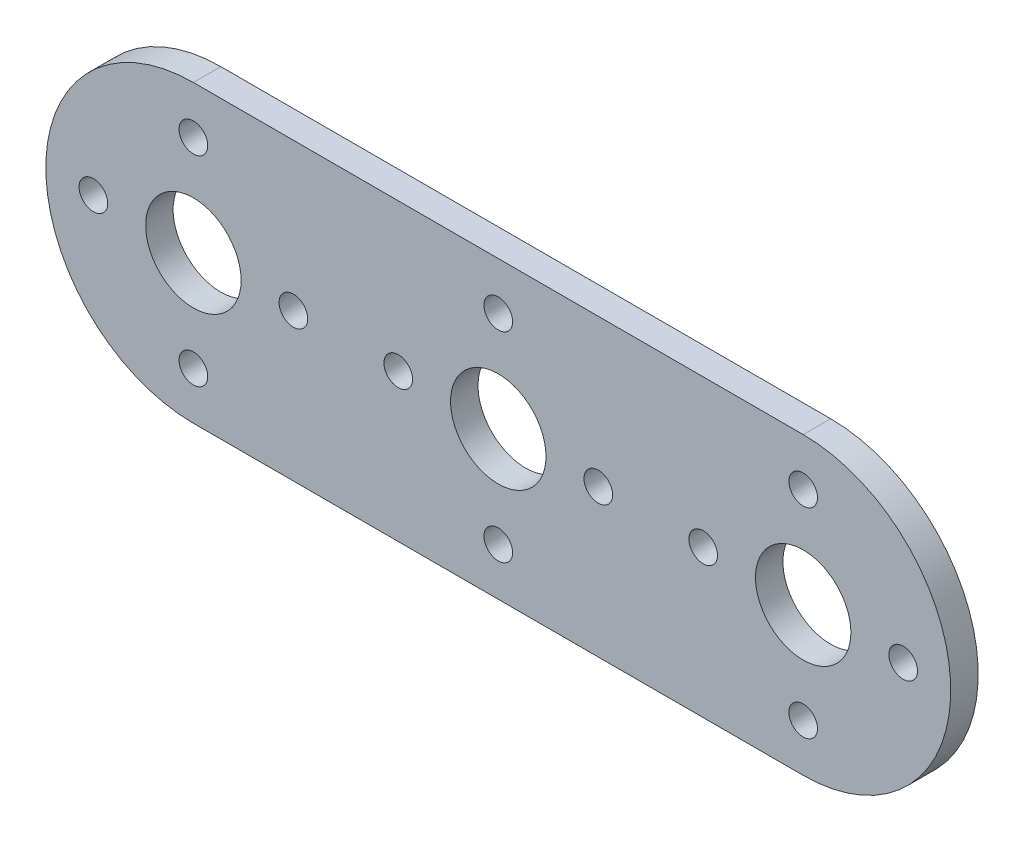
from build123d import *

# Parameters (mm, degrees)
SKETCH1_R      = 3.9751
SKETCH1_R_2    = 1.1938
EXTRUDE1_DEPTH = 2.286


with BuildPart() as part:
    # Sketch1 → Extrude1 (new body)
    with BuildSketch(Plane.XY):
        with BuildLine():
            Line((0, 12.2936), (50.8, 12.2936))
            ThreePointArc((50.8, 12.2936), (63.0936, 0), (50.8, -12.2936))
            Line((50.8, -12.2936), (0, -12.2936))
            ThreePointArc((0, -12.2936), (-12.2936, 0), (0, 12.2936))
        make_face()
        Circle(SKETCH1_R, mode=Mode.SUBTRACT)
        with Locations((0, 8.3312)):
            Circle(SKETCH1_R_2, mode=Mode.SUBTRACT)
        with Locations((8.3312, 0)):
            Circle(SKETCH1_R_2, mode=Mode.SUBTRACT)
        with Locations((0, -8.3312)):
            Circle(SKETCH1_R_2, mode=Mode.SUBTRACT)
        with Locations((-8.3312, 0)):
            Circle(SKETCH1_R_2, mode=Mode.SUBTRACT)
        with Locations((17.0688, 0)):
            Circle(SKETCH1_R_2, mode=Mode.SUBTRACT)
        with Locations((33.7312, 0)):
            Circle(SKETCH1_R_2, mode=Mode.SUBTRACT)
        with Locations((25.4, -8.3312)):
            Circle(SKETCH1_R_2, mode=Mode.SUBTRACT)
        with Locations((25.4, 0)):
            Circle(SKETCH1_R, mode=Mode.SUBTRACT)
        with Locations((25.4, 8.3312)):
            Circle(SKETCH1_R_2, mode=Mode.SUBTRACT)
        with Locations((42.4688, 0)):
            Circle(SKETCH1_R_2, mode=Mode.SUBTRACT)
        with Locations((50.8, -8.3312)):
            Circle(SKETCH1_R_2, mode=Mode.SUBTRACT)
        with Locations((59.1312, 0)):
            Circle(SKETCH1_R_2, mode=Mode.SUBTRACT)
        with Locations((50.8, 8.3312)):
            Circle(SKETCH1_R_2, mode=Mode.SUBTRACT)
        with Locations((50.8, 0)):
            Circle(SKETCH1_R, mode=Mode.SUBTRACT)
    extrude(amount=EXTRUDE1_DEPTH)


solid = part.part
